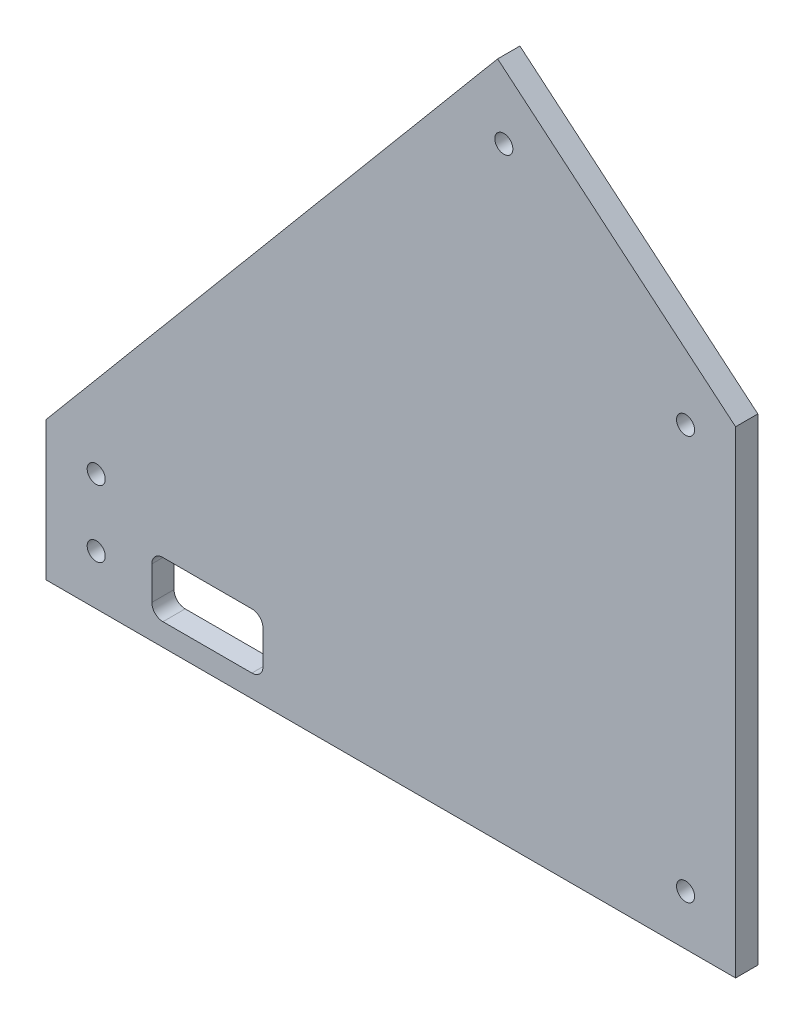
from build123d import *

# Parameters (mm, degrees)
SKETCH1_R           = 1.625
SKETCH1_W           = 20
SKETCH1_H           = 10
BOSS_EXTRUDE1_DEPTH = 4
FILLET1_R           = 2


with BuildPart() as part:
    # Sketch1 → Boss-Extrude1 (new body)
    with BuildSketch(Plane.XY):
        Polygon((-35.731071717, 115.203558257), (4, 81.865230633), (4, -4), (-120, -4), (-120, 0), (-120, 20.998655539), (-38.79524949, 117.774708696), align=None)
        with Locations((-5, 5)):
            Circle(SKETCH1_R, mode=Mode.SUBTRACT)
        with Locations((-111, 5)):
            Circle(SKETCH1_R, mode=Mode.SUBTRACT)
        with Locations((-111, 17)):
            Circle(SKETCH1_R, mode=Mode.SUBTRACT)
        with Locations((-37.685937989, 105.09522022)):
            Circle(SKETCH1_R, mode=Mode.SUBTRACT)
        with Locations((-5, 77.668461709)):
            Circle(SKETCH1_R, mode=Mode.SUBTRACT)
        with Locations((-91, 5)):
            Rectangle(SKETCH1_W, SKETCH1_H, mode=Mode.SUBTRACT)
    extrude(amount=BOSS_EXTRUDE1_DEPTH)

    # Fillet1
    fillet1_edges = [part.edges().sort_by_distance(p)[0] for p in [
        (-101, 10, 2),
        (-101, 0, 2),
        (-81, 0, 2),
        (-81, 10, 2),
    ]]
    fillet(fillet1_edges, radius=FILLET1_R)


solid = part.part
